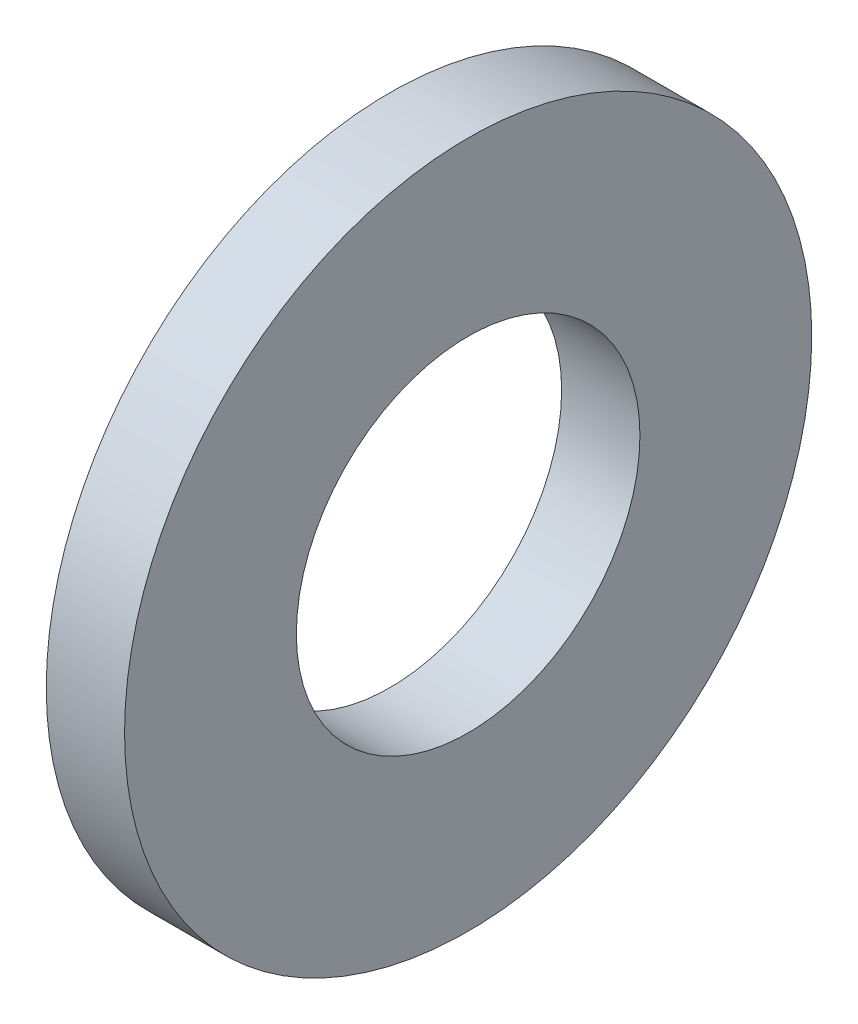
from build123d import *

# Parameters (mm, degrees)
SKETCH1_R           = 13.4874
SKETCH1_R_2         = 6.7437
BOSS_EXTRUDE1_DEPTH = 3.0734


with BuildPart() as part:
    # Sketch1 → Boss-Extrude1 (new body)
    with BuildSketch(Plane(origin=(0, 0, 0), x_dir=(0, 0, -1), z_dir=(1, 0, 0))):
        Circle(SKETCH1_R)
        Circle(SKETCH1_R_2, mode=Mode.SUBTRACT)
    extrude(amount=BOSS_EXTRUDE1_DEPTH)


solid = part.part
